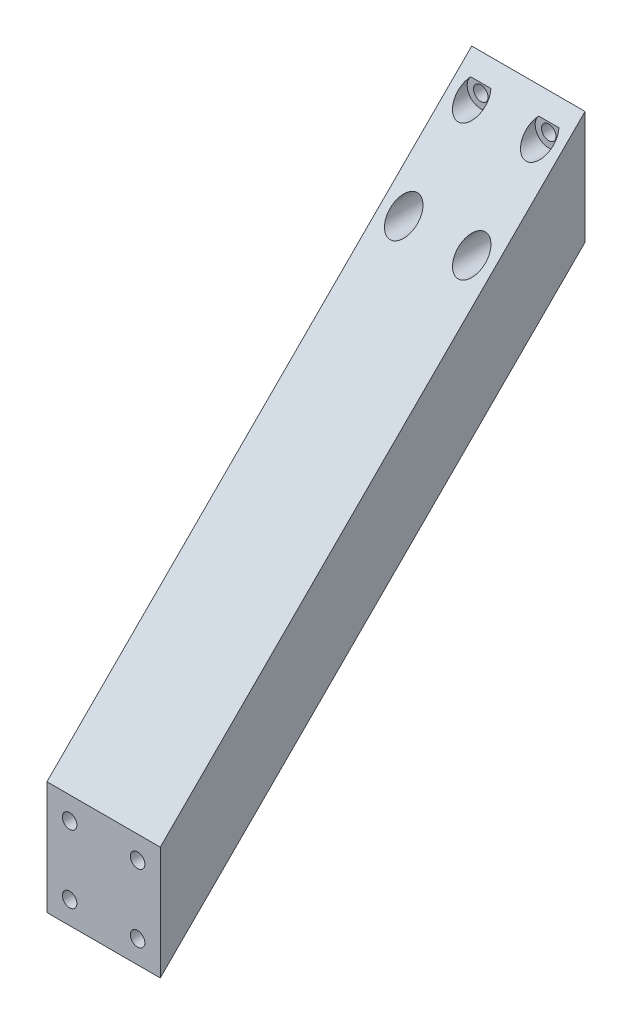
from build123d import *

# Parameters (mm, degrees)
BOSS_EXTRUDE1_DEPTH = 25
CUT_EXTRUDE7_REACH  = 139.863
CUT_EXTRUDE7_START  = -3
SKETCH3_R           = 3
SKETCH3_R_2         = 1.6
CUT_EXTRUDE8_REACH  = 136.863
SKETCH3_3_R         = 1.6
CUT_EXTRUDE9_REACH  = 139.863
CUT_EXTRUDE9_START  = -3
SKETCH4_R           = 3
SKETCH4_R_2         = 1.6
CUT_EXTRUDE10_REACH = 136.863
SKETCH4_2_R         = 1.6


with BuildPart() as part:
    # Sketch1 → Boss-Extrude1 (new body)
    with BuildSketch(Plane(origin=(0, 0, 0), x_dir=(0, 0, -1), z_dir=(1, 0, 0))):
        Polygon((0, 0), (-93.70992099, -93.70992099), (-93.70992099, -68.70992099), (0, 25), align=None)
    extrude(amount=BOSS_EXTRUDE1_DEPTH)

    # Sketch3 → Cut-Extrude7 (cut, up to next)
    with BuildSketch(Plane(origin=(0, 0, 0), x_dir=(-1, 0, 0), z_dir=(0, 0, -1)).offset(CUT_EXTRUDE7_START), mode=Mode.PRIVATE) as cut_extrude7_sk1:
        with Locations((-20, 20)):
            Circle(SKETCH3_R)
        with Locations((-20, 20)):
            Circle(SKETCH3_R_2, mode=Mode.SUBTRACT)
    cut_extrude7_tool1 = extrude(cut_extrude7_sk1.sketch, amount=-CUT_EXTRUDE7_REACH, mode=Mode.PRIVATE) & part.part
    # Sketch3 → Cut-Extrude7 (cut, up to next)
    with BuildSketch(Plane(origin=(0, 0, 0), x_dir=(-1, 0, 0), z_dir=(0, 0, -1)).offset(CUT_EXTRUDE7_START), mode=Mode.PRIVATE) as cut_extrude7_sk2:
        with Locations((-20, 5)):
            Circle(SKETCH3_R)
        with Locations((-20, 5)):
            Circle(SKETCH3_R_2, mode=Mode.SUBTRACT)
    cut_extrude7_tool2 = extrude(cut_extrude7_sk2.sketch, amount=-CUT_EXTRUDE7_REACH, mode=Mode.PRIVATE) & part.part
    # Sketch3 → Cut-Extrude7 (cut, up to next)
    with BuildSketch(Plane(origin=(0, 0, 0), x_dir=(-1, 0, 0), z_dir=(0, 0, -1)).offset(CUT_EXTRUDE7_START), mode=Mode.PRIVATE) as cut_extrude7_sk3:
        with Locations((-5, 5)):
            Circle(SKETCH3_R)
        with Locations((-5, 5)):
            Circle(SKETCH3_R_2, mode=Mode.SUBTRACT)
    cut_extrude7_tool3 = extrude(cut_extrude7_sk3.sketch, amount=-CUT_EXTRUDE7_REACH, mode=Mode.PRIVATE) & part.part
    # Sketch3 → Cut-Extrude7 (cut, up to next)
    with BuildSketch(Plane(origin=(0, 0, 0), x_dir=(-1, 0, 0), z_dir=(0, 0, -1)).offset(CUT_EXTRUDE7_START), mode=Mode.PRIVATE) as cut_extrude7_sk4:
        with Locations((-5, 20)):
            Circle(SKETCH3_R)
        with Locations((-5, 20)):
            Circle(SKETCH3_R_2, mode=Mode.SUBTRACT)
    cut_extrude7_tool4 = extrude(cut_extrude7_sk4.sketch, amount=-CUT_EXTRUDE7_REACH, mode=Mode.PRIVATE) & part.part
    add(cut_extrude7_tool1.solids().sort_by_distance((22.915147, 20, 3))[0], mode=Mode.SUBTRACT)
    add(cut_extrude7_tool2.solids().sort_by_distance((22.915147, 5, 3))[0], mode=Mode.SUBTRACT)
    add(cut_extrude7_tool3.solids().sort_by_distance((7.915147, 5, 3))[0], mode=Mode.SUBTRACT)
    add(cut_extrude7_tool4.solids().sort_by_distance((7.915147, 20, 3))[0], mode=Mode.SUBTRACT)

    # Sketch3_3 → Cut-Extrude8 (cut, up to next)
    with BuildSketch(Plane(origin=(0, 0, 0), x_dir=(-1, 0, 0), z_dir=(0, 0, -1)), mode=Mode.PRIVATE) as cut_extrude8_sk1:
        with Locations((-20, 20)):
            Circle(SKETCH3_3_R)
    cut_extrude8_tool1 = extrude(cut_extrude8_sk1.sketch, amount=-CUT_EXTRUDE8_REACH, mode=Mode.PRIVATE) & part.part
    # Sketch3_3 → Cut-Extrude8 (cut, up to next)
    with BuildSketch(Plane(origin=(0, 0, 0), x_dir=(-1, 0, 0), z_dir=(0, 0, -1)), mode=Mode.PRIVATE) as cut_extrude8_sk2:
        with Locations((-20, 5)):
            Circle(SKETCH3_3_R)
    cut_extrude8_tool2 = extrude(cut_extrude8_sk2.sketch, amount=-CUT_EXTRUDE8_REACH, mode=Mode.PRIVATE) & part.part
    # Sketch3_3 → Cut-Extrude8 (cut, up to next)
    with BuildSketch(Plane(origin=(0, 0, 0), x_dir=(-1, 0, 0), z_dir=(0, 0, -1)), mode=Mode.PRIVATE) as cut_extrude8_sk3:
        with Locations((-5, 5)):
            Circle(SKETCH3_3_R)
    cut_extrude8_tool3 = extrude(cut_extrude8_sk3.sketch, amount=-CUT_EXTRUDE8_REACH, mode=Mode.PRIVATE) & part.part
    # Sketch3_3 → Cut-Extrude8 (cut, up to next)
    with BuildSketch(Plane(origin=(0, 0, 0), x_dir=(-1, 0, 0), z_dir=(0, 0, -1)), mode=Mode.PRIVATE) as cut_extrude8_sk4:
        with Locations((-5, 20)):
            Circle(SKETCH3_3_R)
    cut_extrude8_tool4 = extrude(cut_extrude8_sk4.sketch, amount=-CUT_EXTRUDE8_REACH, mode=Mode.PRIVATE) & part.part
    add(cut_extrude8_tool1.solids().sort_by_distance((20, 20, 0))[0], mode=Mode.SUBTRACT)
    add(cut_extrude8_tool2.solids().sort_by_distance((20, 5, 0))[0], mode=Mode.SUBTRACT)
    add(cut_extrude8_tool3.solids().sort_by_distance((5, 5, 0))[0], mode=Mode.SUBTRACT)
    add(cut_extrude8_tool4.solids().sort_by_distance((5, 20, 0))[0], mode=Mode.SUBTRACT)

    # Sketch4 → Cut-Extrude9 (cut, up to next)
    with BuildSketch(Plane.XY.offset(93.70992099).offset(CUT_EXTRUDE9_START), mode=Mode.PRIVATE) as cut_extrude9_sk1:
        with Locations((5, -73.70992099)):
            Circle(SKETCH4_R)
        with Locations((5, -73.70992099)):
            Circle(SKETCH4_R_2, mode=Mode.SUBTRACT)
    cut_extrude9_tool1 = extrude(cut_extrude9_sk1.sketch, amount=-CUT_EXTRUDE9_REACH, mode=Mode.PRIVATE) & part.part
    # Sketch4 → Cut-Extrude9 (cut, up to next)
    with BuildSketch(Plane.XY.offset(93.70992099).offset(CUT_EXTRUDE9_START), mode=Mode.PRIVATE) as cut_extrude9_sk2:
        with Locations((5, -88.70992099)):
            Circle(SKETCH4_R)
        with Locations((5, -88.70992099)):
            Circle(SKETCH4_R_2, mode=Mode.SUBTRACT)
    cut_extrude9_tool2 = extrude(cut_extrude9_sk2.sketch, amount=-CUT_EXTRUDE9_REACH, mode=Mode.PRIVATE) & part.part
    # Sketch4 → Cut-Extrude9 (cut, up to next)
    with BuildSketch(Plane.XY.offset(93.70992099).offset(CUT_EXTRUDE9_START), mode=Mode.PRIVATE) as cut_extrude9_sk3:
        with Locations((20, -88.70992099)):
            Circle(SKETCH4_R)
        with Locations((20, -88.70992099)):
            Circle(SKETCH4_R_2, mode=Mode.SUBTRACT)
    cut_extrude9_tool3 = extrude(cut_extrude9_sk3.sketch, amount=-CUT_EXTRUDE9_REACH, mode=Mode.PRIVATE) & part.part
    # Sketch4 → Cut-Extrude9 (cut, up to next)
    with BuildSketch(Plane.XY.offset(93.70992099).offset(CUT_EXTRUDE9_START), mode=Mode.PRIVATE) as cut_extrude9_sk4:
        with Locations((20, -73.70992099)):
            Circle(SKETCH4_R)
        with Locations((20, -73.70992099)):
            Circle(SKETCH4_R_2, mode=Mode.SUBTRACT)
    cut_extrude9_tool4 = extrude(cut_extrude9_sk4.sketch, amount=-CUT_EXTRUDE9_REACH, mode=Mode.PRIVATE) & part.part
    add(cut_extrude9_tool1.solids().sort_by_distance((2.084853, -73.709921, 90.709921))[0], mode=Mode.SUBTRACT)
    add(cut_extrude9_tool2.solids().sort_by_distance((2.084853, -88.709921, 90.709921))[0], mode=Mode.SUBTRACT)
    add(cut_extrude9_tool3.solids().sort_by_distance((17.084853, -88.709921, 90.709921))[0], mode=Mode.SUBTRACT)
    add(cut_extrude9_tool4.solids().sort_by_distance((17.084853, -73.709921, 90.709921))[0], mode=Mode.SUBTRACT)

    # Sketch4_2 → Cut-Extrude10 (cut, up to next)
    with BuildSketch(Plane.XY.offset(93.70992099), mode=Mode.PRIVATE) as cut_extrude10_sk1:
        with Locations((5, -73.70992099)):
            Circle(SKETCH4_2_R)
    cut_extrude10_tool1 = extrude(cut_extrude10_sk1.sketch, amount=-CUT_EXTRUDE10_REACH, mode=Mode.PRIVATE) & part.part
    # Sketch4_2 → Cut-Extrude10 (cut, up to next)
    with BuildSketch(Plane.XY.offset(93.70992099), mode=Mode.PRIVATE) as cut_extrude10_sk2:
        with Locations((5, -88.70992099)):
            Circle(SKETCH4_2_R)
    cut_extrude10_tool2 = extrude(cut_extrude10_sk2.sketch, amount=-CUT_EXTRUDE10_REACH, mode=Mode.PRIVATE) & part.part
    # Sketch4_2 → Cut-Extrude10 (cut, up to next)
    with BuildSketch(Plane.XY.offset(93.70992099), mode=Mode.PRIVATE) as cut_extrude10_sk3:
        with Locations((20, -88.70992099)):
            Circle(SKETCH4_2_R)
    cut_extrude10_tool3 = extrude(cut_extrude10_sk3.sketch, amount=-CUT_EXTRUDE10_REACH, mode=Mode.PRIVATE) & part.part
    # Sketch4_2 → Cut-Extrude10 (cut, up to next)
    with BuildSketch(Plane.XY.offset(93.70992099), mode=Mode.PRIVATE) as cut_extrude10_sk4:
        with Locations((20, -73.70992099)):
            Circle(SKETCH4_2_R)
    cut_extrude10_tool4 = extrude(cut_extrude10_sk4.sketch, amount=-CUT_EXTRUDE10_REACH, mode=Mode.PRIVATE) & part.part
    add(cut_extrude10_tool1.solids().sort_by_distance((5, -73.709921, 93.709921))[0], mode=Mode.SUBTRACT)
    add(cut_extrude10_tool2.solids().sort_by_distance((5, -88.709921, 93.709921))[0], mode=Mode.SUBTRACT)
    add(cut_extrude10_tool3.solids().sort_by_distance((20, -88.709921, 93.709921))[0], mode=Mode.SUBTRACT)
    add(cut_extrude10_tool4.solids().sort_by_distance((20, -73.709921, 93.709921))[0], mode=Mode.SUBTRACT)


solid = part.part
